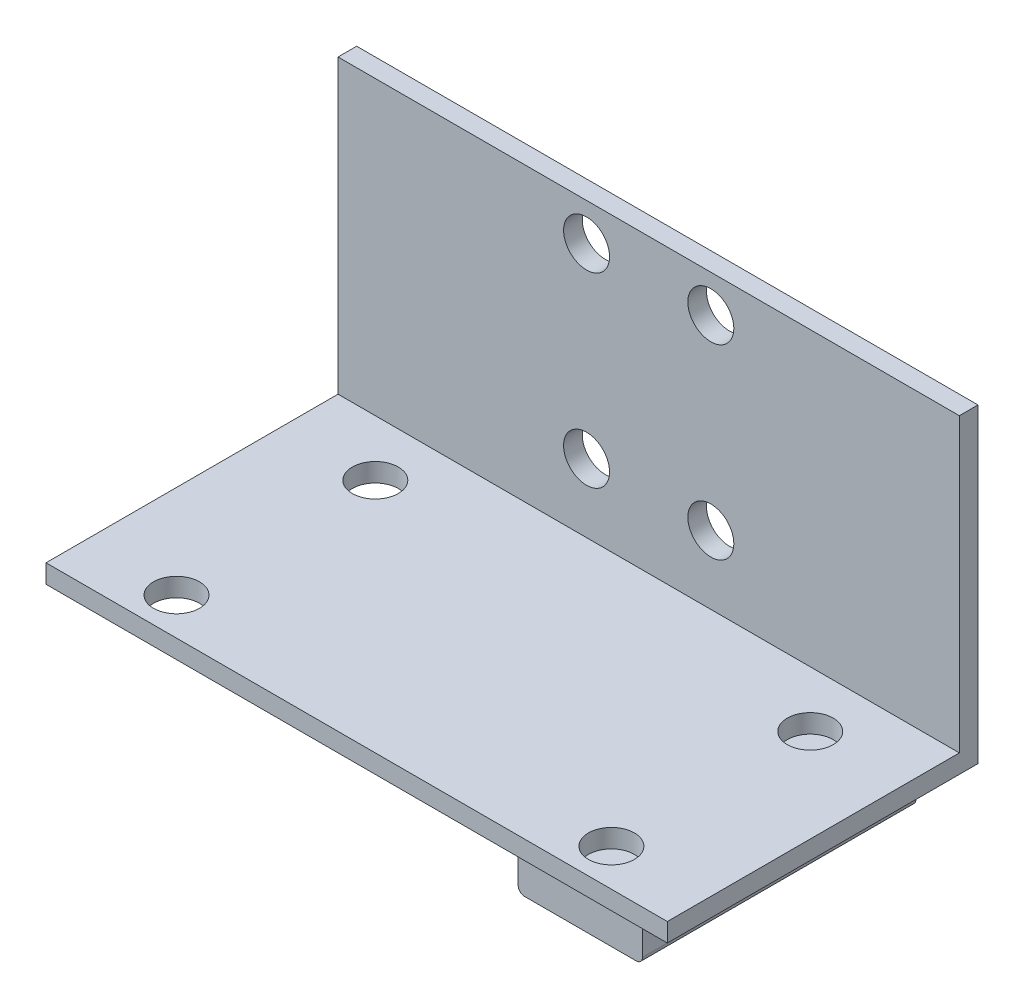
from build123d import *

# Parameters (mm, degrees)
SKETCH1_W           = 50
SKETCH1_H           = 25
BOSS_EXTRUDE1_DEPTH = 1.5
SKETCH3_W           = 50
SKETCH3_H           = 1.5
BOSS_EXTRUDE2_DEPTH = 23.5
SKETCH4_R           = 1.85
CUT_EXTRUDE1_DEPTH  = 23
SKETCH5_R           = 1.85
CUT_EXTRUDE2_DEPTH  = 23
SKETCH6_W           = 10
SKETCH6_H           = 22
BOSS_EXTRUDE3_DEPTH = 3
FILLET1_R           = 0.5


with BuildPart() as part:
    # Sketch1 → Boss-Extrude1 (new body)
    with BuildSketch(Plane(origin=(0, 0, 0), x_dir=(1, 0, 0), z_dir=(0, 1, 0))):
        with Locations((25, 12.5)):
            Rectangle(SKETCH1_W, SKETCH1_H)
    extrude(amount=BOSS_EXTRUDE1_DEPTH)

    # Sketch3 → Boss-Extrude2 (add)
    with BuildSketch(Plane(origin=(0, 1.5, 0), x_dir=(1, 0, 0), z_dir=(0, 1, 0))):
        with Locations((25, 24.25)):
            Rectangle(SKETCH3_W, SKETCH3_H)
    extrude(amount=BOSS_EXTRUDE2_DEPTH)

    # Sketch4 → Cut-Extrude1 (cut)
    with BuildSketch(Plane.XY.offset(-23.5)):
        with Locations((20, 22)):
            Circle(SKETCH4_R)
        with Locations((30, 22)):
            Circle(SKETCH4_R)
        with Locations((30, 7)):
            Circle(SKETCH4_R)
        with Locations((20, 7)):
            Circle(SKETCH4_R)
    extrude(amount=-CUT_EXTRUDE1_DEPTH, mode=Mode.SUBTRACT)

    # Sketch5 → Cut-Extrude2 (cut)
    with BuildSketch(Plane(origin=(0, 1.5, 0), x_dir=(1, 0, 0), z_dir=(0, 1, 0))):
        with Locations((7.5, 3)):
            Circle(SKETCH5_R)
        with Locations((7.5, 19)):
            Circle(SKETCH5_R)
        with Locations((42.5, 3)):
            Circle(SKETCH5_R)
        with Locations((42.5, 19)):
            Circle(SKETCH5_R)
    extrude(amount=-CUT_EXTRUDE2_DEPTH, mode=Mode.SUBTRACT)

    # Sketch6 → Boss-Extrude3 (add)
    with BuildSketch(Plane.XZ):
        with Locations((42.5, -11.5)):
            Rectangle(SKETCH6_W, SKETCH6_H)
    extrude(amount=BOSS_EXTRUDE3_DEPTH)

    # Fillet1
    fillet1_edges = [part.edges().sort_by_distance(p)[0] for p in [
        (47.5, -3, -11.5),
        (37.5, -3, -11.5),
    ]]
    fillet(fillet1_edges, radius=FILLET1_R)


solid = part.part
